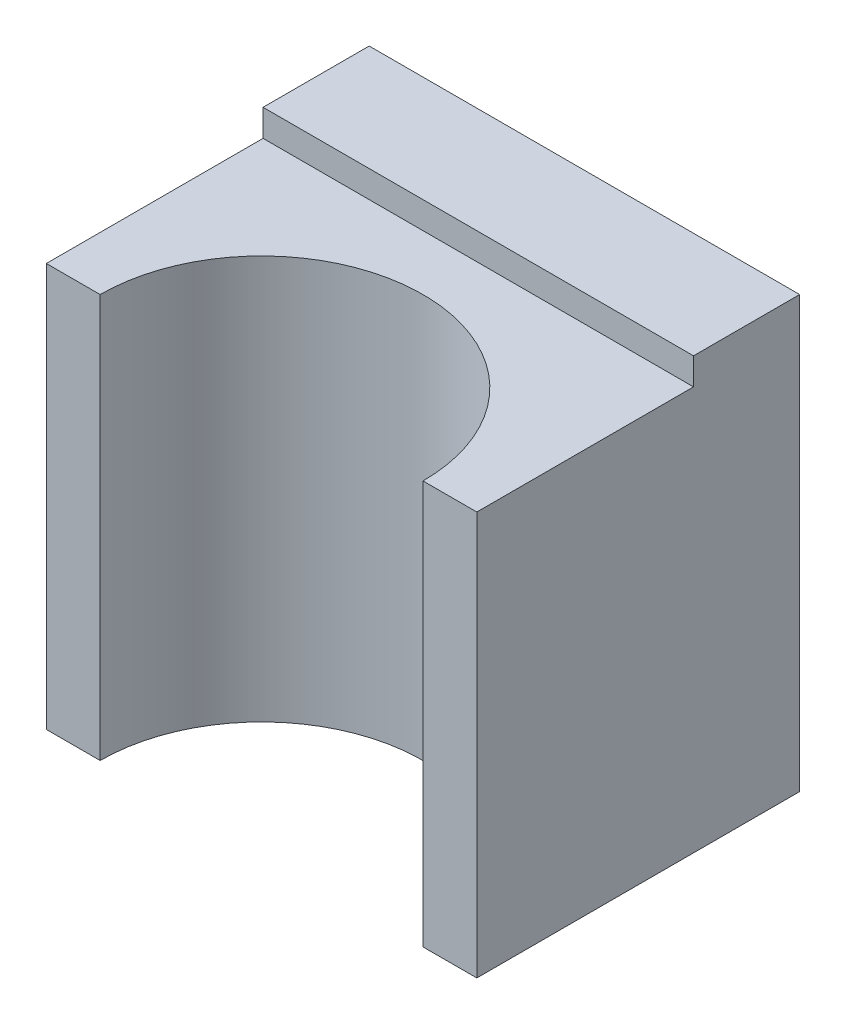
from build123d import *

# Parameters (mm, degrees)
SKETCH1_W           = 40
SKETCH1_H           = 40
BOSS_EXTRUDE1_DEPTH = 30
SKETCH2_R           = 15
CUT_EXTRUDE1_DEPTH  = 41
CUT_EXTRUDE2_DEPTH  = 2.5


with BuildPart() as part:
    # Sketch1 → Boss-Extrude1 (new body)
    with BuildSketch(Plane.XY):
        with Locations((-30, 25)):
            Rectangle(SKETCH1_W, SKETCH1_H)
    extrude(amount=BOSS_EXTRUDE1_DEPTH)

    # Sketch2 → Cut-Extrude1 (cut, through all)
    with BuildSketch(Plane.XZ.offset(-5)):
        with Locations((-30, 30)):
            Circle(SKETCH2_R)
    extrude(amount=-CUT_EXTRUDE1_DEPTH, mode=Mode.SUBTRACT)

    # Sketch3 → Cut-Extrude2 (cut)
    with BuildSketch(Plane(origin=(0, 45, 0), x_dir=(1, 0, 0), z_dir=(0, 1, 0))):
        with BuildLine():
            Line((-10, -30), (-15, -30))
            ThreePointArc((-15, -30), (-30, -15), (-45, -30))
            Line((-45, -30), (-50, -30))
            Line((-50, -30), (-50, -9.862457081))
            Line((-50, -9.862457081), (-10, -9.862457081))
            Line((-10, -9.862457081), (-10, -30))
        make_face()
    extrude(amount=-CUT_EXTRUDE2_DEPTH, mode=Mode.SUBTRACT)


solid = part.part
